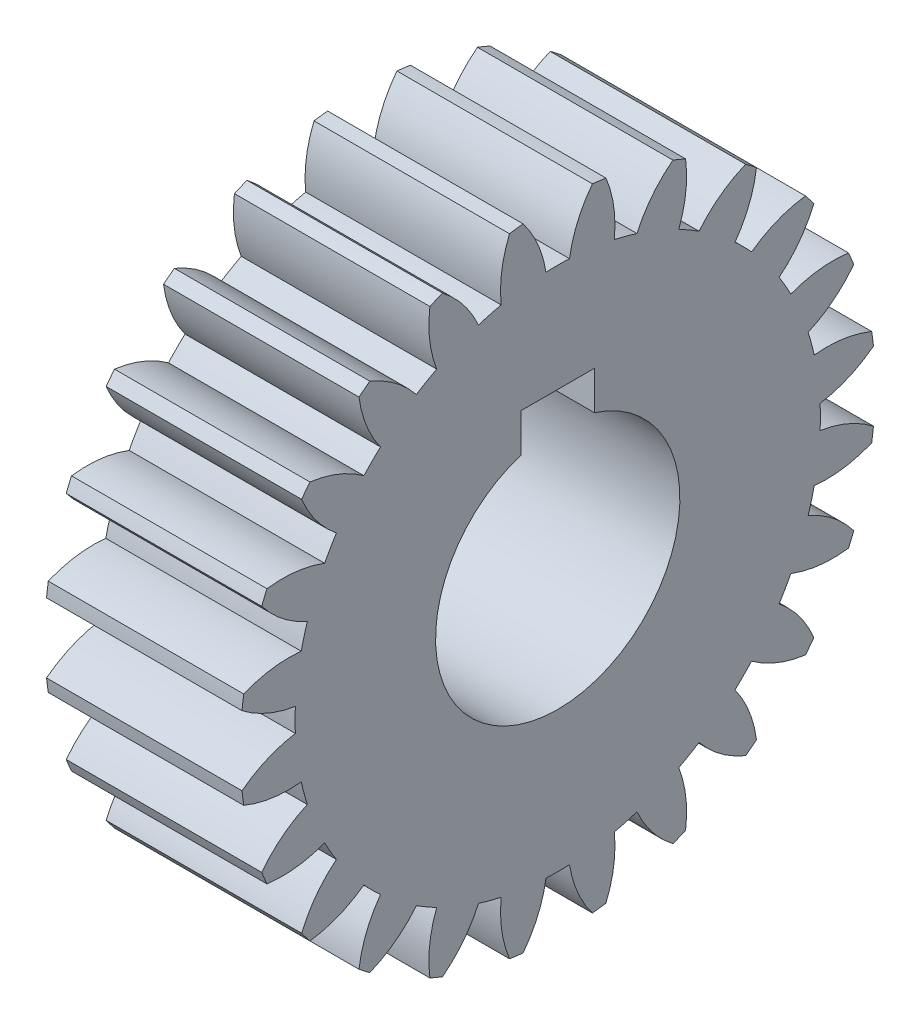
from build123d import *

# Parameters (mm, degrees)
BASPROSKE_W        = 12.7
BASPROSKE_H        = 20.6375
TOOTHCUT_DEPTH     = 32.829276029
TEETHCUTS_COUNT    = 24
TEETHCUTS_ANGLE    = 345
BORSKE_R           = 7.9375
BORE_DEPTH         = 50.8000508
KEYSKE_W           = 4.7625
KEYSKE_H           = 9.2837
KEYWAY_DEPTH       = 50.8000508
SKETCH2_W          = 4.7625
SKETCH2_H          = 0.7874
CUT_EXTRUDE2_DEPTH = 32.669469117


with BuildPart() as part:
    # BasProSke → Base-Revolve (revolve)
    with BuildSketch(Plane(origin=(0, 0, 0), x_dir=(1, 0, 0), z_dir=(0, 1, 0)), mode=Mode.PRIVATE) as base_revolve_sk:
        with Locations((6.35, 10.31875)):
            Rectangle(BASPROSKE_W, BASPROSKE_H)
    revolve(base_revolve_sk.sketch.rotate(Axis((-10, 0, 0), (1, 0, 0)), 180), axis=Axis((-10, 0, 0), (1, 0, 0)))

    # TooCutSke → ToothCut (cut, through all)
    with BuildSketch(Plane(origin=(0, 0, 0), x_dir=(0, 0, -1), z_dir=(1, 0, 0))):
        with BuildLine():
            ThreePointArc((0.762542858, 17.047308877), (0, 17.064355), (-0.762542858, 17.047308877))
            ThreePointArc((-0.762542858, 17.047308877), (-1.295412414, 18.888113288), (-2.270705673, 20.537753824))
            ThreePointArc((-2.270705673, 20.537753824), (0, 20.6629), (2.270705673, 20.537753824))
            ThreePointArc((2.270705673, 20.537753824), (1.295412414, 18.888113288), (0.762542858, 17.047308877))
        make_face()
    toothcut = extrude(amount=TOOTHCUT_DEPTH, mode=Mode.SUBTRACT)

    # TeethCuts: ToothCut ×24 about axis
    teethcuts_axis = Axis((-10, 0, 0), (1, 0, 0))
    for i in range(1, TEETHCUTS_COUNT):
        add(toothcut.rotate(teethcuts_axis, i * TEETHCUTS_ANGLE / (TEETHCUTS_COUNT - 1)), mode=Mode.SUBTRACT)

    # BorSke → Bore (cut, symmetric)
    with BuildSketch(Plane(origin=(0, 0, 0), x_dir=(0, 0, -1), z_dir=(1, 0, 0))):
        with Locations(Location((0, 0, 0), (0, 0, 180))):
            Circle(BORSKE_R)
    extrude(amount=BORE_DEPTH, both=True, mode=Mode.SUBTRACT)

    # KeySke → Keyway (cut, symmetric)
    with BuildSketch(Plane(origin=(0, 0, 0), x_dir=(0, 0, -1), z_dir=(1, 0, 0))):
        with Locations((0, 4.64185)):
            Rectangle(KEYSKE_W, KEYSKE_H)
    extrude(amount=KEYWAY_DEPTH, both=True, mode=Mode.SUBTRACT)

    # Sketch2 → Cut-Extrude2 (cut, through all)
    with BuildSketch(Plane(origin=(12.7, 0, 0), x_dir=(0, 0, -1), z_dir=(1, 0, 0))):
        with Locations((0, 9.6774)):
            Rectangle(SKETCH2_W, SKETCH2_H)
    extrude(amount=-CUT_EXTRUDE2_DEPTH, mode=Mode.SUBTRACT)


solid = part.part
